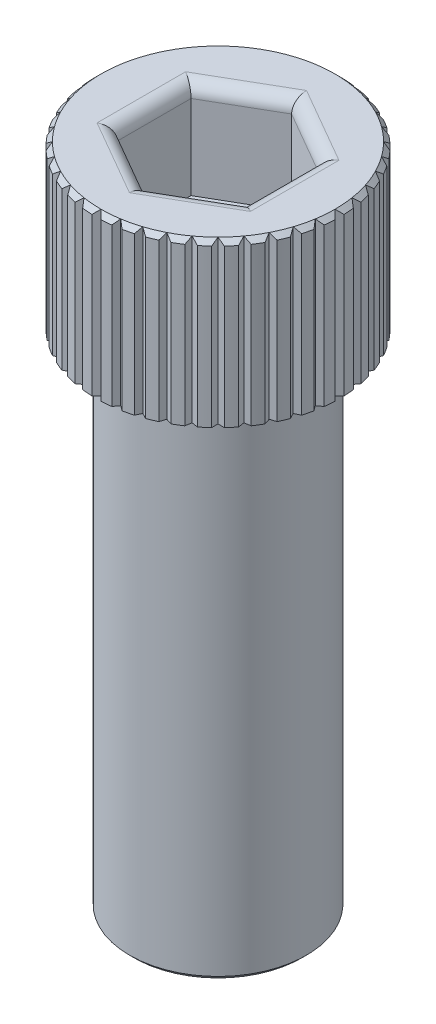
from build123d import *

# Parameters (mm, degrees)
CUT_EXTRUDE1_DEPTH = 3.81
FILLET1_R          = 0.508
CUT_EXTRUDE2_DEPTH = 6.604
CIRPATTERN1_COUNT  = 40


with BuildPart() as part:
    # Sketch1 → Revolve1 (revolve)
    with BuildSketch(Plane.XY):
        Polygon((0, 0), (0, 26.1112), (4.595594878, 26.1112), (4.7752, 25.931594878), (4.7752, 19.7612), (3.4671, 19.7612), (3.4671, 0.179605122), (3.287494878, 0), align=None)
    revolve(axis=Axis((0, 0, 0), (0, 1, 0)))

    # Sketch2 → Cut-Extrude1 (cut)
    with BuildSketch(Plane(origin=(0, 26.1112, 0), x_dir=(1, 0, 0), z_dir=(0, 1, 0))):
        Polygon((0, -2.88925), (2.502163898, -1.444625), (2.502163898, 1.444625), (0, 2.88925), (-2.502163898, 1.444625), (-2.502163898, -1.444625), align=None)
    extrude(amount=-CUT_EXTRUDE1_DEPTH, mode=Mode.SUBTRACT)

    # Fillet1
    fillet1_edges = [part.edges().sort_by_distance(p)[0] for p in [
        (-1.251081949, 26.1112, 2.1669375),
        (1.251081949, 26.1112, 2.1669375),
        (2.502163898, 26.1112, 0),
        (1.251081949, 26.1112, -2.1669375),
        (-1.251081949, 26.1112, -2.1669375),
        (-2.502163898, 26.1112, 0),
    ]]
    fillet(fillet1_edges, radius=FILLET1_R)

    # Sketch3 → Cut-Extrude2 (cut)
    with BuildSketch(Plane(origin=(0, 26.1112, 0), x_dir=(1, 0, 0), z_dir=(0, 1, 0))):
        Polygon((-0.635, 5.230594878), (0, 4.595594878), (0.635, 5.230594878), align=None)
    cut_extrude2 = extrude(amount=-CUT_EXTRUDE2_DEPTH, mode=Mode.SUBTRACT)

    # CirPattern1: Cut-Extrude2 ×40 about axis
    cirpattern1_axis = Axis((0, 0, 0), (0, 1, 0))
    for i in range(1, CIRPATTERN1_COUNT):
        add(cut_extrude2.rotate(cirpattern1_axis, i * 360 / CIRPATTERN1_COUNT), mode=Mode.SUBTRACT)


solid = part.part
